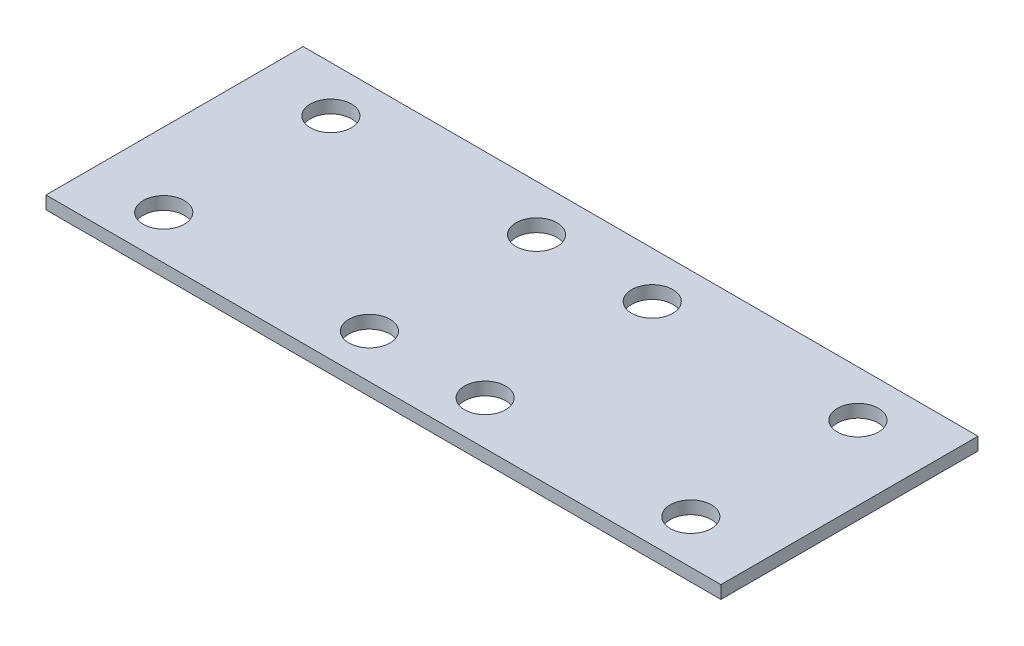
from build123d import *

# Parameters (mm, degrees)
SKETCH1_W           = 52.5
SKETCH1_H           = 20
BOSS_EXTRUDE1_DEPTH = 1
SKETCH2_R           = 1.6
CUT_EXTRUDE1_DEPTH  = 2


with BuildPart() as part:
    # Sketch1 → Boss-Extrude1 (new body)
    with BuildSketch(Plane(origin=(0, 0, 0), x_dir=(1, 0, 0), z_dir=(0, 1, 0))):
        Rectangle(SKETCH1_W, SKETCH1_H)
    extrude(amount=BOSS_EXTRUDE1_DEPTH)

    # Sketch2 → Cut-Extrude1 (cut)
    with BuildSketch(Plane(origin=(0, 1, 0), x_dir=(1, 0, 0), z_dir=(0, 1, 0))):
        with Locations((-20.5, 6.409092896)):
            Circle(SKETCH2_R)
        with Locations((-4.5, 6.409092896)):
            Circle(SKETCH2_R)
        with Locations((4.5, 6.409092896)):
            Circle(SKETCH2_R)
        with Locations((20.5, 6.409092896)):
            Circle(SKETCH2_R)
        with Locations((-20.5, -6.590907104)):
            Circle(SKETCH2_R)
        with Locations((-4.5, -6.590907104)):
            Circle(SKETCH2_R)
        with Locations((4.5, -6.590907104)):
            Circle(SKETCH2_R)
        with Locations((20.5, -6.590907104)):
            Circle(SKETCH2_R)
    extrude(amount=-CUT_EXTRUDE1_DEPTH, mode=Mode.SUBTRACT)


solid = part.part
